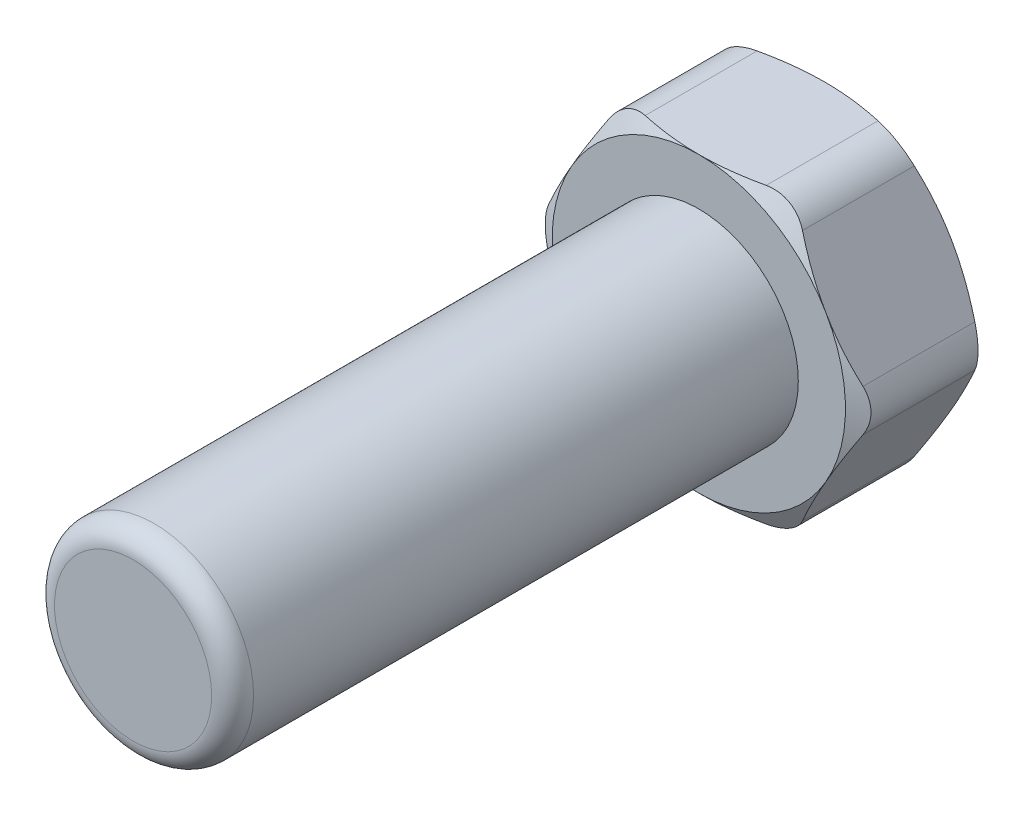
from build123d import *

# Parameters (mm, degrees)
BOSS_EXTRUDE2_DEPTH     = 1.5
SKETCH5_OUTSIDE_W       = 64.264
SKETCH5_OUTSIDE_H       = 63.182
SKETCH5_OUTSIDE_R       = 3.5
CUT_EXTRUDE1_DEPTH      = 15
CUT_EXTRUDE1_DRAFT      = -60
MIRROR1_COPY_1_SKETCH_W = 64.264
MIRROR1_COPY_1_SKETCH_H = 63.182
MIRROR1_COPY_1_SKETCH_R = 3.5
MIRROR1_COPY_1_DEPTH    = 15
MIRROR1_COPY_1_DRAFT    = -60
SKETCH4_3_R             = 2.375
BOSS_EXTRUDE3_DEPTH     = 15
FILLET1_R               = 1
FILLET2_R               = 0.5


with BuildPart() as part:
    # Sketch4 → Boss-Extrude2 (new, symmetric)
    with BuildSketch(Plane.XY):
        Polygon((2.020725942, 3.5), (-2.020725942, 3.5), (-4.041451884, 0), (-2.020725942, -3.5), (2.020725942, -3.5), (4.041451884, 0), align=None)
    extrude(amount=BOSS_EXTRUDE2_DEPTH, both=True)


with BuildPart() as cut_extrude1_tool:
    # Sketch5 outside → Cut-Extrude1 (with draft: the straight prism first)
    with BuildSketch(Plane.XY.offset(1.5)):
        Rectangle(SKETCH5_OUTSIDE_W, SKETCH5_OUTSIDE_H)
        Circle(SKETCH5_OUTSIDE_R, mode=Mode.SUBTRACT)
    extrude(amount=-CUT_EXTRUDE1_DEPTH)
    # Cut-Extrude1: the draft: its side faces are tilted about the plane it starts from
    cut_extrude1_sides = [cut_extrude1_tool.faces().sort_by_distance(p)[0] for p in [
        (0, -31.591, -6),
        (32.132, 0, -6),
        (0, 31.591, -6),
        (-32.132, 0, -6),
        (-3.5, 0, -6),
    ]]
    draft(cut_extrude1_sides, Plane.XY.offset(1.5), CUT_EXTRUDE1_DRAFT)


with BuildPart() as part_1:
    add(part.part)

    # Cut-Extrude1: cut by cut_extrude1_tool
    add(cut_extrude1_tool.part, mode=Mode.SUBTRACT)


with BuildPart() as mirror1_copy_1_tool:
    # Mirror1 copy 1 sketch → Mirror1 copy 1 (with draft: the straight prism first)
    with BuildSketch(Plane(origin=(0, 0, -1.5), x_dir=(1, 0, 0), z_dir=(0, 0, -1))):
        Rectangle(MIRROR1_COPY_1_SKETCH_W, MIRROR1_COPY_1_SKETCH_H)
        Circle(MIRROR1_COPY_1_SKETCH_R, mode=Mode.SUBTRACT)
    extrude(amount=-MIRROR1_COPY_1_DEPTH)
    # Mirror1 copy 1: the draft: its side faces are tilted about the plane it starts from
    mirror1_copy_1_sides = [mirror1_copy_1_tool.faces().sort_by_distance(p)[0] for p in [
        (0, -31.591, 6),
        (32.132, 0, 6),
        (0, 31.591, 6),
        (-32.132, 0, 6),
        (-3.5, 0, 6),
    ]]
    draft(mirror1_copy_1_sides, Plane(origin=(0, 0, -1.5), x_dir=(1, 0, 0), z_dir=(0, 0, -1)), MIRROR1_COPY_1_DRAFT)


with BuildPart() as part_2:
    add(part_1.part)

    # Mirror1 copy 1: cut by mirror1_copy_1_tool
    add(mirror1_copy_1_tool.part, mode=Mode.SUBTRACT)

    # Sketch4_3 → Boss-Extrude3 (add)
    with BuildSketch(Plane.XY):
        Circle(SKETCH4_3_R)
    extrude(amount=BOSS_EXTRUDE3_DEPTH)

    # Fillet1
    fillet1_edges = [part_2.edges().sort_by_distance(p)[0] for p in [
        (4.041451884, 0, 0),
        (2.020725942, -3.5, 0),
        (-2.020725942, -3.5, 0),
        (-4.041451884, 0, 0),
        (-2.020725942, 3.5, 0),
        (2.020725942, 3.5, 0),
    ]]
    fillet(fillet1_edges, radius=FILLET1_R)

    # Fillet2
    fillet2_edges = [part_2.edges().sort_by_distance(p)[0] for p in [
        (-2.375, 0, 15),
    ]]
    fillet(fillet2_edges, radius=FILLET2_R)


solid = part_2.part
